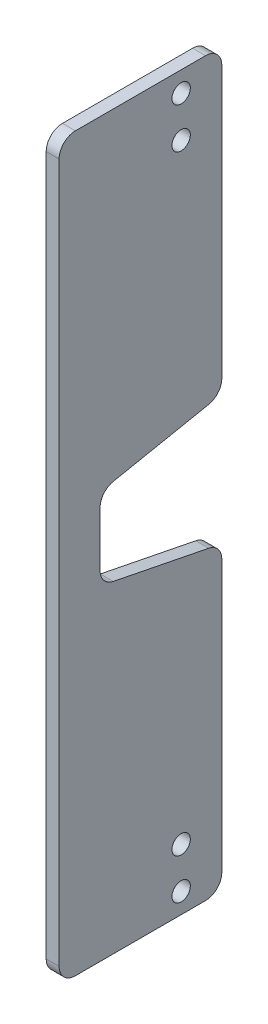
from build123d import *

# Parameters (mm, degrees)
SKETCH_1_R      = 1.1303
EXTRUDE_1_DEPTH = 1.588
FILLET_1_R      = 2
FILLET_2_R      = 2
FILLET_3_R      = 2
FILLET_4_R      = 2


with BuildPart() as part:
    # 草图1 → 凸台-拉伸1 (new body)
    with BuildSketch(Plane(origin=(-0.79375, 0, 0), x_dir=(0, -1, 0), z_dir=(-1, 0, 0))):
        with BuildLine():
            Line((38.795, 5), (12.795, 5))
            ThreePointArc((12.795, 5), (11.380786438, 4.414213562), (10.795, 3))
            Line((10.795, 3), (10.795, -13))
            ThreePointArc((10.795, -13), (11.380786438, -14.414213562), (12.795, -15))
            Line((12.795, -15), (47.795, -15))
            Line((47.795, -15), (50.77, -0.039144756))
            Line((50.77, -0.039144756), (55.77, -0.039144756))
            Line((55.77, -0.039144756), (60.77, -0.039144756))
            Line((60.77, -0.039144756), (63.745, -15))
            Line((63.745, -15), (98.745, -15))
            ThreePointArc((98.745, -15), (100.159213562, -14.414213562), (100.745, -13))
            Line((100.745, -13), (100.745, 3))
            ThreePointArc((100.745, 3), (100.159213562, 4.414213562), (98.745, 5))
            Line((98.745, 5), (72.745, 5))
            Line((72.745, 5), (38.795, 5))
        make_face()
        with Locations((13.295, -10)):
            Circle(SKETCH_1_R, mode=Mode.SUBTRACT)
        with Locations((18.295, -10)):
            Circle(SKETCH_1_R, mode=Mode.SUBTRACT)
        with Locations((93.245, -10)):
            Circle(SKETCH_1_R, mode=Mode.SUBTRACT)
        with Locations((98.245, -10)):
            Circle(SKETCH_1_R, mode=Mode.SUBTRACT)
    extrude(amount=-EXTRUDE_1_DEPTH)

    # 圆角1
    fillet_1_edges = [part.edges().sort_by_distance(p)[0] for p in [
        (0.00025, -47.795, -15),
    ]]
    fillet(fillet_1_edges, radius=FILLET_1_R)

    # 圆角2
    fillet_2_edges = [part.edges().sort_by_distance(p)[0] for p in [
        (0.00025, -50.77, -0.039144756),
    ]]
    fillet(fillet_2_edges, radius=FILLET_2_R)

    # 圆角3
    fillet_3_edges = [part.edges().sort_by_distance(p)[0] for p in [
        (0.00025, -60.77, -0.039144756),
    ]]
    fillet(fillet_3_edges, radius=FILLET_3_R)

    # 圆角4
    fillet_4_edges = [part.edges().sort_by_distance(p)[0] for p in [
        (0.00025, -63.745, -15),
    ]]
    fillet(fillet_4_edges, radius=FILLET_4_R)


solid = part.part
